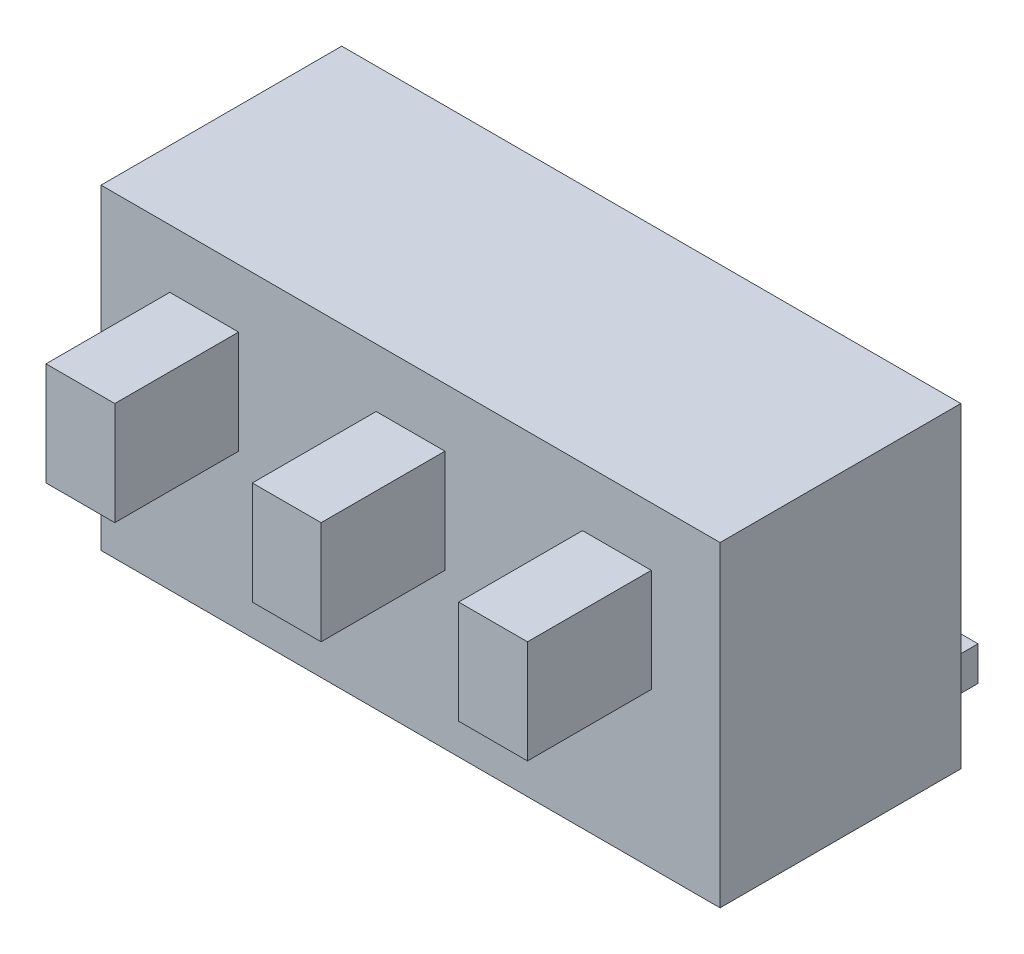
from build123d import *

# Parameters (mm, degrees)
SKETCH1_W            = 9
SKETCH1_H            = 3.5
BOSS_EXTRUDE1_DEPTH  = 4.6
SKETCH2_W            = 1
SKETCH2_H            = 1.5
BOSS_EXTRUDE2_DEPTH  = 1.8
LPATTERN1_COUNT      = 2
LPATTERN1_PITCH      = 3
LPATTERN1_COUNT_DIR2 = 2
LPATTERN1_PITCH_DIR2 = 3
SKETCH5_R            = 0.35
BOSS_EXTRUDE4_DEPTH  = 0.7
SKETCH3_W            = 1.1
SKETCH3_H            = 0.5
BOSS_EXTRUDE3_DEPTH  = 1.2
LPATTERN2_COUNT      = 2
LPATTERN2_PITCH      = 3
LPATTERN2_COL_COUNT  = 2
LPATTERN2_COL_PITCH  = 3


with BuildPart() as part:
    # Sketch1 → Boss-Extrude1 (new body)
    with BuildSketch(Plane(origin=(0, 0, 0), x_dir=(1, 0, 0), z_dir=(0, 1, 0))):
        Rectangle(SKETCH1_W, SKETCH1_H)
    extrude(amount=BOSS_EXTRUDE1_DEPTH)

    # Sketch2 → Boss-Extrude2 (add)
    with BuildSketch(Plane.XY.offset(1.75)):
        with Locations((0, 3)):
            Rectangle(SKETCH2_W, SKETCH2_H)
    boss_extrude2 = extrude(amount=BOSS_EXTRUDE2_DEPTH)

    # LPattern1: Boss-Extrude2 2 × 2
    with Locations(*[Vector(1, 0, 0) * (i * LPATTERN1_PITCH) + Vector(-1, 0, 0) * (j * LPATTERN1_PITCH_DIR2) for i in range(LPATTERN1_COUNT) for j in range(LPATTERN1_COUNT_DIR2) if (i, j) != (0, 0)]):
        add(boss_extrude2)

    # Sketch5 → Boss-Extrude4 (add)
    with BuildSketch(Plane.XZ):
        with Locations((-1.5, -1.15)):
            Circle(SKETCH5_R)
        with Locations((1.5, -1.15)):
            Circle(SKETCH5_R)
    extrude(amount=BOSS_EXTRUDE4_DEPTH)

    # Sketch3 → Boss-Extrude3 (add)
    with BuildSketch(Plane(origin=(0, 0, -1.75), x_dir=(-1, 0, 0), z_dir=(0, 0, -1))):
        with Locations((0, 0.25)):
            Rectangle(SKETCH3_W, SKETCH3_H)
    boss_extrude3 = extrude(amount=BOSS_EXTRUDE3_DEPTH)

    # LPattern2: Boss-Extrude3 ×2
    with Locations(*[(i * LPATTERN2_PITCH, 0, 0) for i in range(1, LPATTERN2_COUNT)]):
        add(boss_extrude3)

    # LPattern2 col: Boss-Extrude3 ×2
    with Locations(*[(-i * LPATTERN2_COL_PITCH, 0, 0) for i in range(1, LPATTERN2_COL_COUNT)]):
        add(boss_extrude3)


solid = part.part
